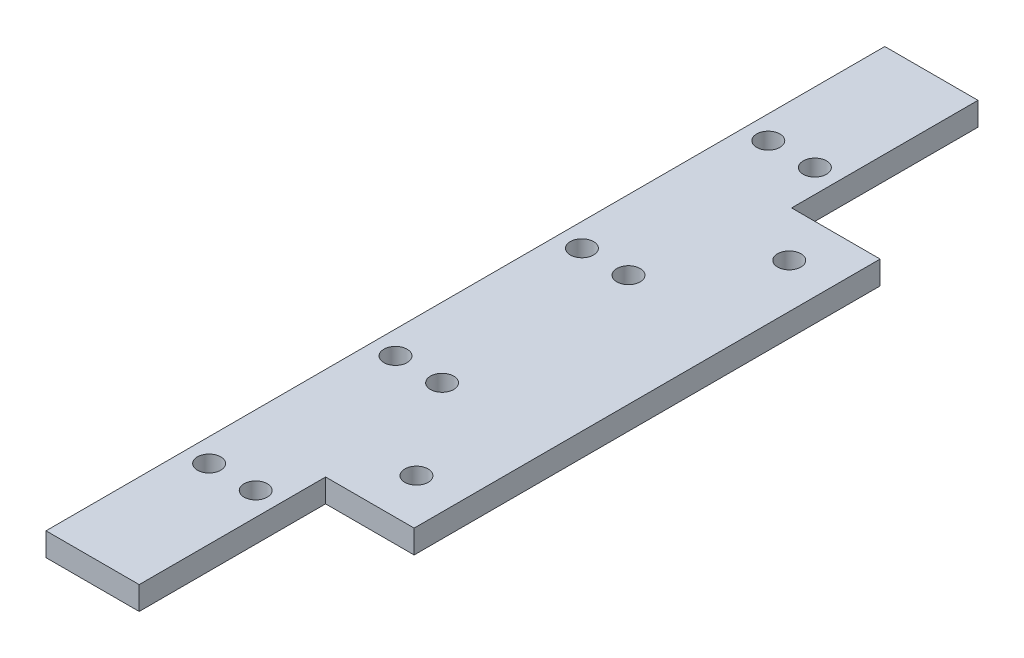
from build123d import *

# Parameters (mm, degrees)
SKETCH1_W           = 24.13
SKETCH1_H           = 127
BOSS_EXTRUDE1_DEPTH = 6.35
CUT_EXTRUDE2_DEPTH  = 7.35
SKETCH5_W           = 127
SKETCH5_H           = 6.35
BOSS_EXTRUDE2_DEPTH = 25.4
SKETCH6_W           = 25.4
SKETCH6_H           = 6.35
BOSS_EXTRUDE3_DEPTH = 50.8
SKETCH7_W           = 25.4
SKETCH7_H           = 6.35
BOSS_EXTRUDE4_DEPTH = 50.8
SKETCH8_R           = 3.175
CUT_EXTRUDE3_DEPTH  = 7.35


with BuildPart() as part:
    # Sketch1 → Boss-Extrude1 (new body)
    with BuildSketch(Plane(origin=(0, 0, 0), x_dir=(1, 0, 0), z_dir=(0, 1, 0))):
        with Locations((12.065, 63.5)):
            Rectangle(SKETCH1_W, SKETCH1_H)
    extrude(amount=BOSS_EXTRUDE1_DEPTH)

    # Sketch3 → Cut-Extrude2 (cut, through all)
    with BuildSketch(Plane(origin=(0, 6.35, 0), x_dir=(1, 0, 0), z_dir=(0, 1, 0))):
        with BuildLine():
            ThreePointArc((12.065, 117.475), (8.89, 114.3), (12.065, 111.125))
            Line((12.065, 111.125), (12.065, 117.475))
        make_face()
        with BuildLine():
            Line((12.065, 117.475), (12.065, 111.125))
            ThreePointArc((12.065, 111.125), (14.31006403, 112.05493597), (15.24, 114.3))
            ThreePointArc((15.24, 114.3), (14.31006403, 116.54506403), (12.065, 117.475))
        make_face()
        with BuildLine():
            ThreePointArc((12.065, 15.875), (8.89, 12.7), (12.065, 9.525))
            Line((12.065, 9.525), (12.065, 12.7))
            Line((12.065, 12.7), (12.065, 15.875))
        make_face()
        with BuildLine():
            Line((12.065, 12.7), (12.065, 9.525))
            ThreePointArc((12.065, 9.525), (14.31006403, 10.45493597), (15.24, 12.7))
            ThreePointArc((15.24, 12.7), (14.31006403, 14.94506403), (12.065, 15.875))
            Line((12.065, 15.875), (12.065, 12.7))
        make_face()
    extrude(amount=-CUT_EXTRUDE2_DEPTH, mode=Mode.SUBTRACT)

    # Sketch5 → Boss-Extrude2 (add)
    with BuildSketch(Plane.ZY):
        with Locations((-63.5, 3.175)):
            Rectangle(SKETCH5_W, SKETCH5_H)
    extrude(amount=BOSS_EXTRUDE2_DEPTH)

    # Sketch6 → Boss-Extrude3 (add)
    with BuildSketch(Plane.XY):
        with Locations((-12.7, 3.175)):
            Rectangle(SKETCH6_W, SKETCH6_H)
    extrude(amount=BOSS_EXTRUDE3_DEPTH)

    # Sketch7 → Boss-Extrude4 (add)
    with BuildSketch(Plane(origin=(0, 0, -127), x_dir=(-1, 0, 0), z_dir=(0, 0, -1))):
        with Locations((12.7, 3.175)):
            Rectangle(SKETCH7_W, SKETCH7_H)
    extrude(amount=BOSS_EXTRUDE4_DEPTH)

    # Sketch8 → Cut-Extrude3 (cut, through all)
    with BuildSketch(Plane(origin=(0, 6.35, 0), x_dir=(1, 0, 0), z_dir=(0, 1, 0))):
        with BuildLine():
            ThreePointArc((-3.175, 139.7), (-6.35, 142.875), (-9.525, 139.7))
            Line((-9.525, 139.7), (-3.175, 139.7))
        make_face()
        with BuildLine():
            Line((-3.175, 139.7), (-9.525, 139.7))
            ThreePointArc((-9.525, 139.7), (-6.35, 136.525), (-3.175, 139.7))
        make_face()
        with Locations(Location((-19.05, 139.7, 0), (0, 0, 270))):  # turned: the seam where the file's is
            Circle(SKETCH8_R)
        with Locations(Location((-19.05, 88.9, 0), (0, 0, 270))):  # turned: the seam where the file's is
            Circle(SKETCH8_R)
        with Locations(Location((-6.35, 88.9, 0), (0, 0, 270))):  # turned: the seam where the file's is
            Circle(SKETCH8_R)
        with Locations(Location((-19.05, 38.1, 0), (0, 0, 270))):  # turned: the seam where the file's is
            Circle(SKETCH8_R)
        with Locations(Location((-6.35, 38.1, 0), (0, 0, 270))):  # turned: the seam where the file's is
            Circle(SKETCH8_R)
        with Locations(Location((-6.35, -12.7, 0), (0, 0, 270))):  # turned: the seam where the file's is
            Circle(SKETCH8_R)
        with Locations(Location((-19.05, -12.7, 0), (0, 0, 270))):  # turned: the seam where the file's is
            Circle(SKETCH8_R)
    extrude(amount=-CUT_EXTRUDE3_DEPTH, mode=Mode.SUBTRACT)


solid = part.part
